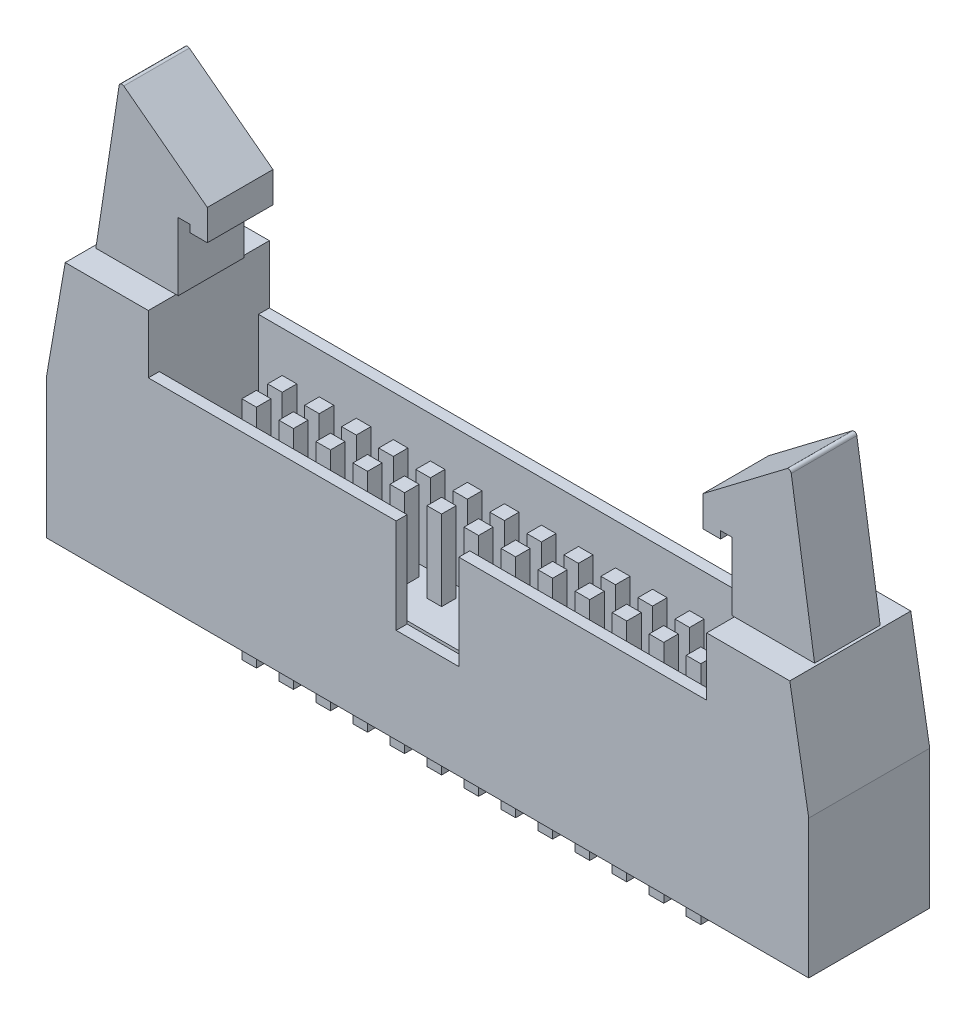
from build123d import *

# Parameters (mm, degrees)
EXTRUDE_1_DEPTH      = 8.3
SKETCH_2_W           = 38.3
SKETCH_2_H           = 6.8
CUT_EXTRUDE_1_DEPTH  = 6.3
SKETCH_3_W           = 4.3
SKETCH_3_H           = 6.5
CUT_EXTRUDE_2_DEPTH  = 0.75
EXTRUDE_2_DEPTH      = 4.5
SKETCH_6_W           = 1
SKETCH_6_H           = 1
EXTRUDE_3_DEPTH      = 5.5
EXTRUDE_3_DEPTH_BACK = 10


with BuildPart() as part:
    # 草图1 → 凸台-拉伸1 (new body)
    with BuildSketch(Plane.XY):
        Polygon((-26.15, 9.5), (-26.15, 0), (26.15, 0), (26.15, 9.5), (24.85, 17), (19.15, 17), (19.15, 13), (-19.15, 13), (-19.15, 17), (-24.85, 17), align=None)
    extrude(amount=EXTRUDE_1_DEPTH)

    # 草图2 → 切除-拉伸1 (cut)
    with BuildSketch(Plane(origin=(0, 13, 0), x_dir=(1, 0, 0), z_dir=(0, 1, 0))):
        with Locations((0, -4.15)):
            Rectangle(SKETCH_2_W, SKETCH_2_H)
    extrude(amount=-CUT_EXTRUDE_1_DEPTH, mode=Mode.SUBTRACT)

    # 草图3 → 切除-拉伸2 (cut)
    with BuildSketch(Plane.XY.offset(8.3)):
        with Locations((0, 9.75)):
            Rectangle(SKETCH_3_W, SKETCH_3_H)
    extrude(amount=-CUT_EXTRUDE_2_DEPTH, mode=Mode.SUBTRACT)

    # 草图4 → 凸台-拉伸2 (add)
    with BuildSketch(Plane(origin=(0, 0, 1.9), x_dir=(-1, 0, 0), z_dir=(0, 0, -1))):
        with BuildLine():
            Line((-24.65, 17), (-23.050757977, 27.467765972))
            ThreePointArc((-23.050757977, 27.467765972), (-22.928198831, 27.622906391), (-22.732203771, 27.596921193))
            Line((-22.732203771, 27.596921193), (-17, 23.25))
            Line((-17, 23.25), (-17, 21.15))
            Line((-17, 21.15), (-18.2, 21.15))
            Line((-18.2, 21.15), (-18.2, 21.65))
            Line((-18.2, 21.65), (-19, 21.65))
            Line((-19, 21.65), (-19, 17))
            Line((-19, 17), (-24.65, 17))
        make_face()
        with BuildLine():
            Line((19, 17), (24.65, 17))
            Line((24.65, 17), (23.050757977, 27.467765972))
            ThreePointArc((23.050757977, 27.467765972), (22.928198831, 27.622906391), (22.732203771, 27.596921193))
            Line((22.732203771, 27.596921193), (17, 23.25))
            Line((17, 23.25), (17, 21.15))
            Line((17, 21.15), (18.2, 21.15))
            Line((18.2, 21.15), (18.2, 21.65))
            Line((18.2, 21.65), (19, 21.65))
            Line((19, 21.65), (19, 17))
        make_face()
    extrude(amount=-EXTRUDE_2_DEPTH)

    # 草图6 → 凸台-拉伸3 (add, two sides)
    with BuildSketch(Plane(origin=(0, 6.7, 0), x_dir=(1, 0, 0), z_dir=(0, 1, 0))) as extrude_3_sk:
        with Locations((7.86, -3.265)):
            Rectangle(SKETCH_6_W, SKETCH_6_H)
        with Locations((-15, -5.035)):
            Rectangle(SKETCH_6_W, SKETCH_6_H)
        with Locations((-12.46, -5.035)):
            Rectangle(SKETCH_6_W, SKETCH_6_H)
        with Locations((-9.92, -5.035)):
            Rectangle(SKETCH_6_W, SKETCH_6_H)
        with Locations((-7.38, -5.035)):
            Rectangle(SKETCH_6_W, SKETCH_6_H)
        with Locations((-4.84, -5.035)):
            Rectangle(SKETCH_6_W, SKETCH_6_H)
        with Locations((-2.3, -5.035)):
            Rectangle(SKETCH_6_W, SKETCH_6_H)
        with Locations((0.24, -5.035)):
            Rectangle(SKETCH_6_W, SKETCH_6_H)
        with Locations((2.78, -5.035)):
            Rectangle(SKETCH_6_W, SKETCH_6_H)
        with Locations((5.32, -5.035)):
            Rectangle(SKETCH_6_W, SKETCH_6_H)
        with Locations((7.86, -5.035)):
            Rectangle(SKETCH_6_W, SKETCH_6_H)
        with Locations((5.32, -3.265)):
            Rectangle(SKETCH_6_W, SKETCH_6_H)
        with Locations((2.78, -3.265)):
            Rectangle(SKETCH_6_W, SKETCH_6_H)
        with Locations((0.24, -3.265)):
            Rectangle(SKETCH_6_W, SKETCH_6_H)
        with Locations((-2.3, -3.265)):
            Rectangle(SKETCH_6_W, SKETCH_6_H)
        with Locations((-4.84, -3.265)):
            Rectangle(SKETCH_6_W, SKETCH_6_H)
        with Locations((-7.38, -3.265)):
            Rectangle(SKETCH_6_W, SKETCH_6_H)
        with Locations((-9.92, -3.265)):
            Rectangle(SKETCH_6_W, SKETCH_6_H)
        with Locations((-12.46, -3.265)):
            Rectangle(SKETCH_6_W, SKETCH_6_H)
        with Locations((-15, -3.265)):
            Rectangle(SKETCH_6_W, SKETCH_6_H)
        with Locations((10.4, -5.035)):
            Rectangle(SKETCH_6_W, SKETCH_6_H)
        with Locations((12.94, -5.035)):
            Rectangle(SKETCH_6_W, SKETCH_6_H)
        with Locations((15.48, -5.035)):
            Rectangle(SKETCH_6_W, SKETCH_6_H)
        with Locations((10.4, -3.265)):
            Rectangle(SKETCH_6_W, SKETCH_6_H)
        with Locations((12.94, -3.265)):
            Rectangle(SKETCH_6_W, SKETCH_6_H)
        with Locations((15.48, -3.265)):
            Rectangle(SKETCH_6_W, SKETCH_6_H)
    extrude(amount=EXTRUDE_3_DEPTH)
    extrude(extrude_3_sk.sketch, amount=-EXTRUDE_3_DEPTH_BACK)


solid = part.part
